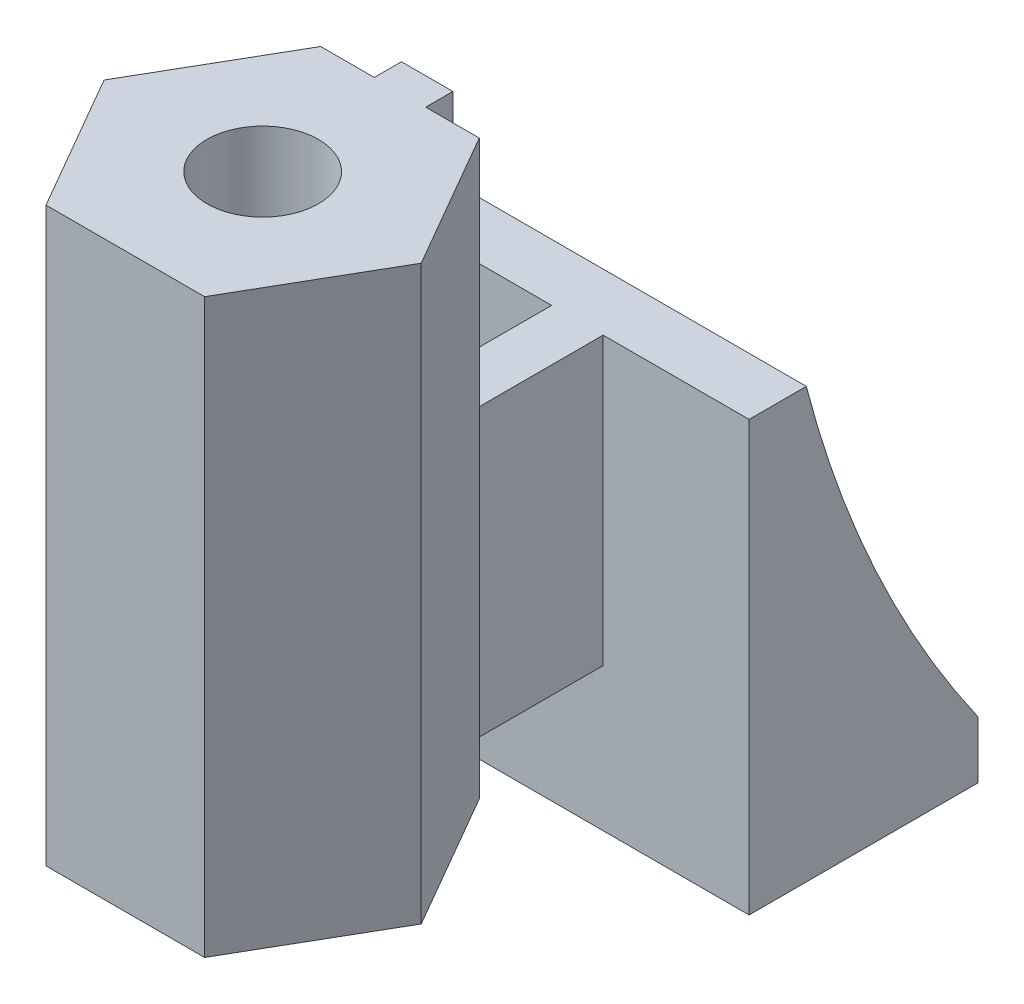
from build123d import *

# Parameters (mm, degrees)
BOSS_EXTRUDE1_DEPTH = 20
SKETCH4_R           = 1.95
CUT_EXTRUDE1_DEPTH  = 20
BOSS_EXTRUDE2_DEPTH = 10
SKETCH8_W           = 12
SKETCH8_H           = 8
BOSS_EXTRUDE3_DEPTH = 5
CUT_EXTRUDE3_REACH  = 14


with BuildPart() as part:
    # Sketch2 → Boss-Extrude1 (new body)
    with BuildSketch(Plane(origin=(0, 0, 0), x_dir=(1, 0, 0), z_dir=(0, 1, 0))):
        Polygon((5.542562584, 0), (2.771281292, 4.8), (0.9, 4.8), (0.9, 5.75), (-0.9, 5.75), (-0.9, 4.8), (-2.771281292, 4.8), (-5.542562584, 0), (-2.771281292, -4.8), (2.771281292, -4.8), align=None)
    extrude(amount=BOSS_EXTRUDE1_DEPTH)

    # Sketch4 → Cut-Extrude1 (cut)
    with BuildSketch(Plane(origin=(0, 0, 0), x_dir=(-1, 0, 0), z_dir=(0, -1, 0))):
        Circle(SKETCH4_R)
    extrude(amount=-CUT_EXTRUDE1_DEPTH, mode=Mode.SUBTRACT)

    # Sketch6 → Boss-Extrude2 (add)
    with BuildSketch(Plane.XZ):
        Polygon((0.9, -5.75), (0.9, -11), (6, -11), (6, -19), (-6, -19), (-6, -11), (-0.9, -11), (-0.9, -5.75), align=None)
    extrude(amount=-BOSS_EXTRUDE2_DEPTH)

    # Sketch8 → Boss-Extrude3 (add)
    with BuildSketch(Plane(origin=(0, 0, 0), x_dir=(-1, 0, 0), z_dir=(0, -1, 0))):
        with Locations((0, 15)):
            Rectangle(SKETCH8_W, SKETCH8_H)
    extrude(amount=BOSS_EXTRUDE3_DEPTH)

    # Sketch9 → Cut-Extrude3 (cut, up to next)
    with BuildSketch(Plane(origin=(6, 0, 0), x_dir=(0, 0, -1), z_dir=(1, 0, 0)), mode=Mode.PRIVATE) as cut_extrude3_sk1:
        with BuildLine():
            Line((13, 10), (19, 10))
            Line((19, 10), (19, -3))
            ThreePointArc((19, -3), (15.413604557, 3.22935595), (13, 10))
        make_face()
    cut_extrude3_tool1 = extrude(cut_extrude3_sk1.sketch, amount=-CUT_EXTRUDE3_REACH, mode=Mode.PRIVATE) & part.part
    add(cut_extrude3_tool1.solids().sort_by_distance((6, 5.355709, -16.831232))[0], mode=Mode.SUBTRACT)


solid = part.part
